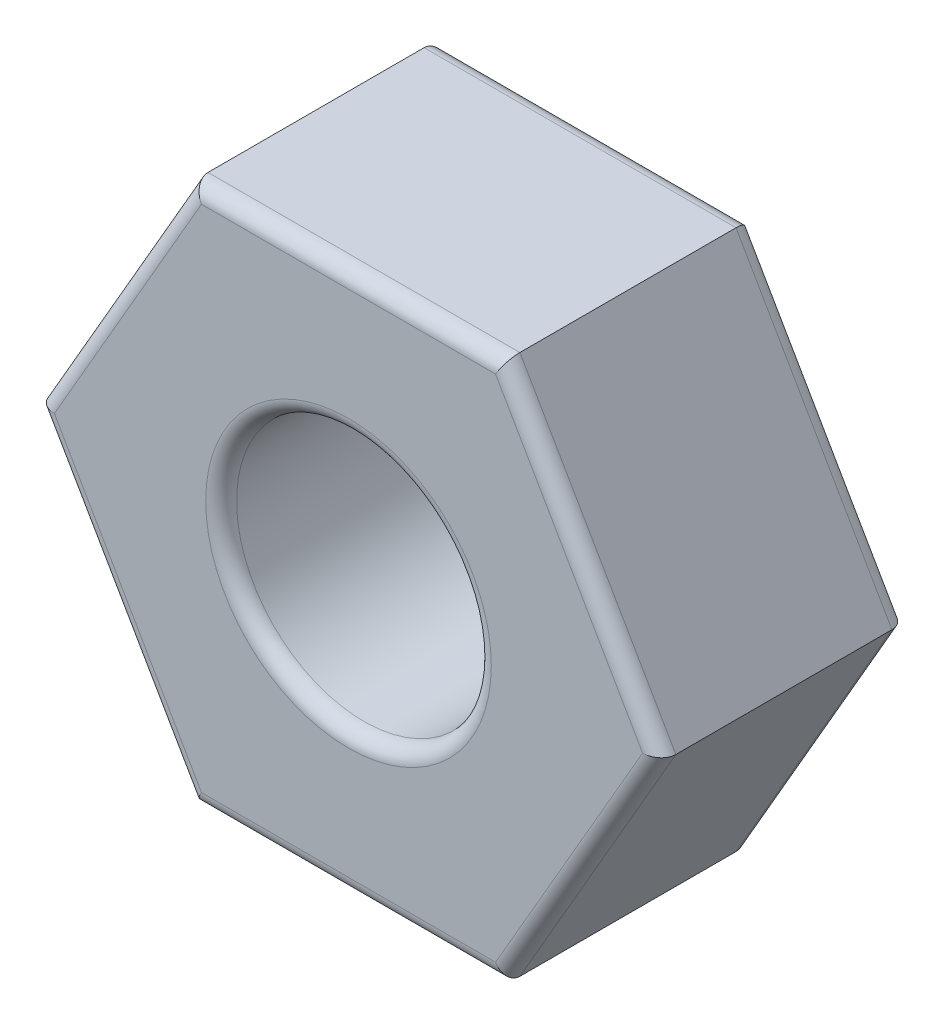
from build123d import *

# Parameters (mm, degrees)
SKETCH1_R           = 1.65
BOSS_EXTRUDE1_DEPTH = 3.2
FILLET1_R           = 0.2


with BuildPart() as part:
    # Sketch1 → Boss-Extrude1 (new body)
    with BuildSketch(Plane.XY):
        Polygon((4.041451884, 0), (2.020725942, 3.5), (-2.020725942, 3.5), (-4.041451884, 0), (-2.020725942, -3.5), (2.020725942, -3.5), align=None)
        Circle(SKETCH1_R, mode=Mode.SUBTRACT)
    extrude(amount=BOSS_EXTRUDE1_DEPTH)

    # Fillet1
    fillet1_edges = [part.edges().sort_by_distance(p)[0] for p in [
        (0, 3.5, 3.2),
        (-3.031088913, 1.75, 3.2),
        (-3.031088913, -1.75, 3.2),
        (-1.65, 0, 0),
        (-1.65, 0, 3.2),
        (0, -3.5, 3.2),
        (3.031088913, -1.75, 3.2),
        (0, -3.5, 0),
        (-3.031088913, -1.75, 0),
        (-3.031088913, 1.75, 0),
        (3.031088913, 1.75, 3.2),
        (0, 3.5, 0),
        (3.031088913, 1.75, 0),
        (3.031088913, -1.75, 0),
    ]]
    fillet(fillet1_edges, radius=FILLET1_R)


solid = part.part
